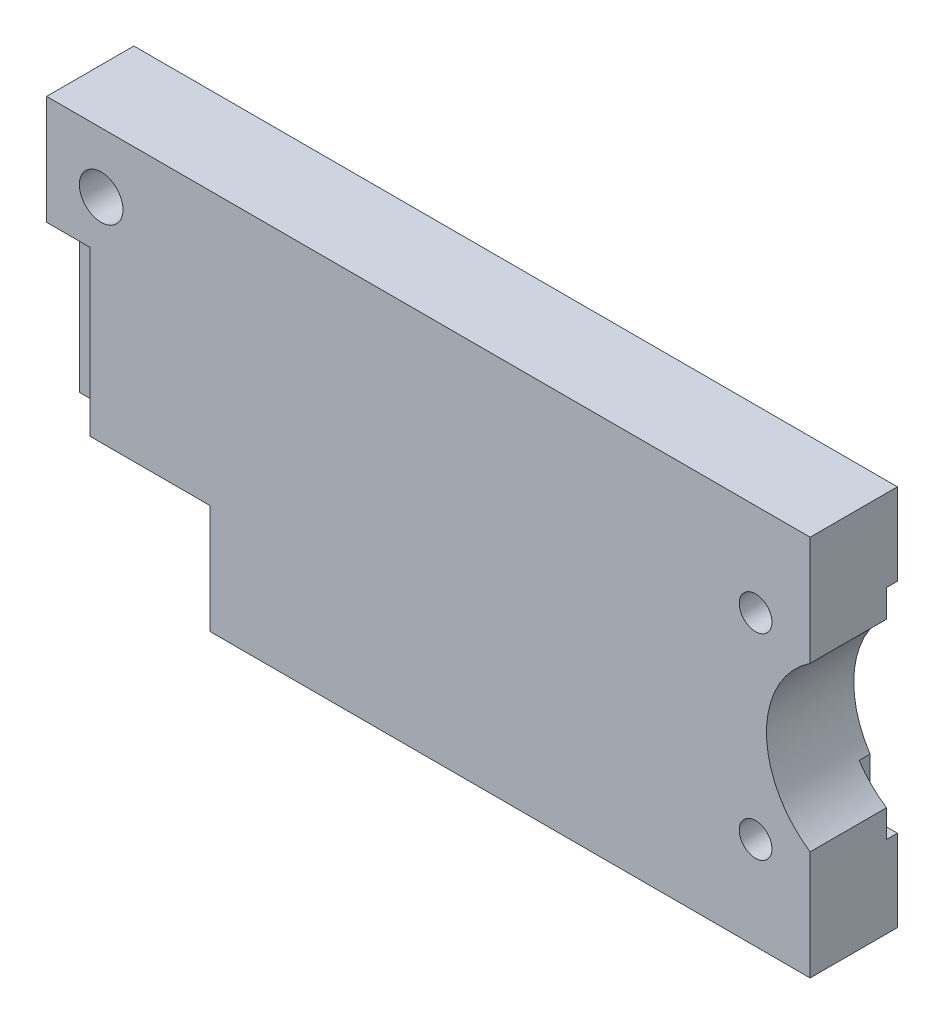
from build123d import *

# Parameters (mm, degrees)
SKETCH1_R           = 2
BOSS_EXTRUDE1_DEPTH = 4
SKETCH2_W           = 4
SKETCH2_H           = 15
CUT_EXTRUDE1_DEPTH  = 3
SKETCH3_W           = 2.5
SKETCH3_H           = 20
CUT_EXTRUDE2_DEPTH  = 1
CUT_EXTRUDE3_REACH  = 10
SKETCH5_R           = 9


with BuildPart() as part:
    # Sketch1 → Boss-Extrude1 (new body, symmetric)
    with BuildSketch(Plane.XY):
        Polygon((-20, -17.5), (35, -17.5), (35, 17.5), (-35, 17.5), (-35, -7.5), (-20, -7.5), align=None)
        with BuildLine():
            ThreePointArc((31.5, -9), (28.939339828, -10.060660172), (30, -7.5))
            ThreePointArc((30, -7.5), (31.060660172, -7.939339828), (31.5, -9))
        make_face(mode=Mode.SUBTRACT)
        with Locations((-30, 12)):
            Circle(SKETCH1_R, mode=Mode.SUBTRACT)
        with BuildLine():
            ThreePointArc((31.5, 9), (31.060660172, 7.939339828), (30, 7.5))
            ThreePointArc((30, 7.5), (28.939339828, 10.060660172), (31.5, 9))
        make_face(mode=Mode.SUBTRACT)
    extrude(amount=BOSS_EXTRUDE1_DEPTH, both=True)

    # Sketch2 → Cut-Extrude1 (cut)
    with BuildSketch(Plane.XY.offset(4)):
        with Locations((-33, 0)):
            Rectangle(SKETCH2_W, SKETCH2_H)
    extrude(amount=-CUT_EXTRUDE1_DEPTH, mode=Mode.SUBTRACT)

    # Sketch3 → Cut-Extrude2 (cut)
    with BuildSketch(Plane(origin=(0, 0, -4), x_dir=(-1, 0, 0), z_dir=(0, 0, -1))):
        with Locations((-33.75, 0)):
            Rectangle(SKETCH3_W, SKETCH3_H)
    extrude(amount=-CUT_EXTRUDE2_DEPTH, mode=Mode.SUBTRACT)

    # Sketch5 → Cut-Extrude3 (cut, up to next)
    with BuildSketch(Plane.XY.offset(4), mode=Mode.PRIVATE) as cut_extrude3_sk1:
        with Locations((40, 0)):
            Circle(SKETCH5_R)
    cut_extrude3_tool1 = extrude(cut_extrude3_sk1.sketch, amount=-CUT_EXTRUDE3_REACH, mode=Mode.PRIVATE) & part.part
    add(cut_extrude3_tool1.solids().sort_by_distance((40, 0, 4))[0], mode=Mode.SUBTRACT)


solid = part.part
